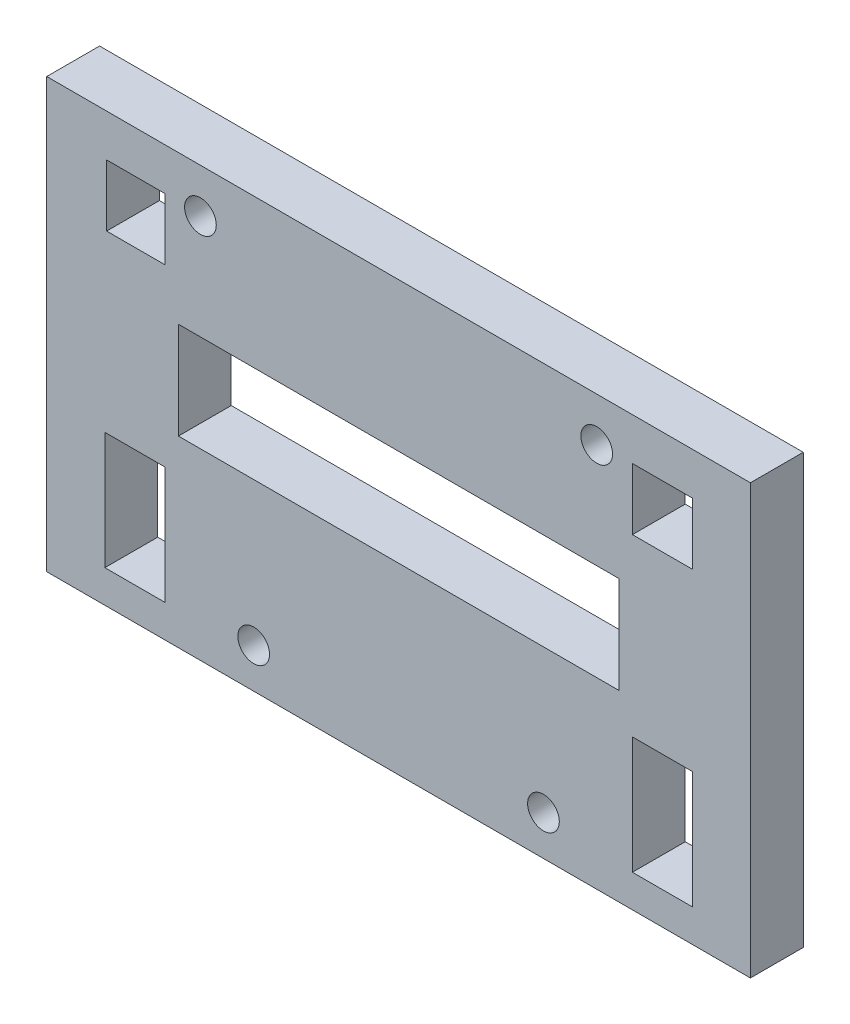
from build123d import *

# Parameters (mm, degrees)
MODEL_W                  = 79.9
MODEL_H                  = 48.698269882
MODEL_R                  = 1.8
MODEL_W_2                = 6.8
MODEL_H_2                = 13.312275424
MODEL_W_3                = 6.6
MODEL_H_3                = 7
MODEL_W_4                = 49.999979697
MODEL_H_4                = 10.999995003
RESSALTO_EXTRUS_O1_DEPTH = 6


with BuildPart() as part:
    # Model → Ressalto-extrusão1 (new body)
    with BuildSketch(Plane.XY):
        with Locations((70.266607808, 31.590543985)):
            Rectangle(MODEL_W, MODEL_H)
        with Locations((53.816607808, 11.757142514)):
            Circle(MODEL_R, mode=Mode.SUBTRACT)
        with Locations((92.766607808, 50.939678926)):
            Circle(MODEL_R, mode=Mode.SUBTRACT)
        with Locations((86.716607808, 11.757142514)):
            Circle(MODEL_R, mode=Mode.SUBTRACT)
        with Locations((47.766607808, 50.939678926)):
            Circle(MODEL_R, mode=Mode.SUBTRACT)
        with Locations((40.316607808, 17.595816638)):
            Rectangle(MODEL_W_2, MODEL_H_2, mode=Mode.SUBTRACT)
        with Locations((40.416607808, 47.639678926)):
            Rectangle(MODEL_W_3, MODEL_H_3, mode=Mode.SUBTRACT)
        with Locations((100.216607808, 17.595816638)):
            Rectangle(MODEL_W_2, MODEL_H_2, mode=Mode.SUBTRACT)
        with Locations((100.216607808, 47.639678926)):
            Rectangle(MODEL_W_2, MODEL_H_3, mode=Mode.SUBTRACT)
        with Locations((70.266607808, 33.557142515)):
            Rectangle(MODEL_W_4, MODEL_H_4, mode=Mode.SUBTRACT)
    extrude(amount=RESSALTO_EXTRUS_O1_DEPTH)


solid = part.part
